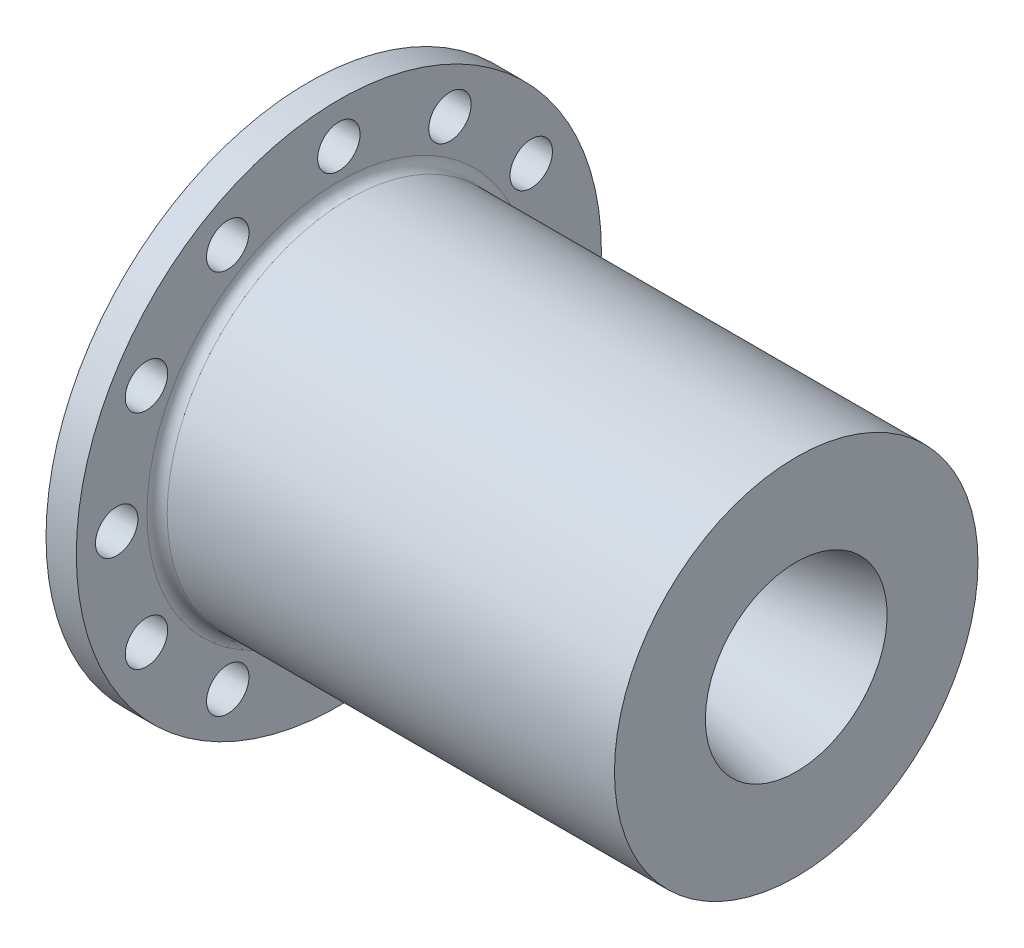
from build123d import *

# Parameters (mm, degrees)
FILLET1_R          = 1.27
SKETCH2_R          = 2.667
CUT_EXTRUDE1_DEPTH = 3.81
CIRPATTERN1_COUNT  = 12
FILLET2_R          = 0.254


with BuildPart() as part:
    # Chamber Revolve → Revolve1 (revolve)
    with BuildSketch(Plane.XY):
        Polygon((3.81, 22.86), (61.331753256, 22.86), (61.331753256, 11.43), (43.197991731, 7.57555), (41.673991731, 7.57555), (38.1, 15.24), (0, 15.24), (0, 19.304), (1.016, 19.304), (1.016, 21.844), (0, 21.844), (0, 33.02), (3.81, 33.02), align=None)
    revolve(axis=Axis((0, 0, 0), (1, 0, 0)))

    # Fillet1
    fillet1_edges = [part.edges().sort_by_distance(p)[0] for p in [
        (3.81, -22.86, 0),
    ]]
    fillet(fillet1_edges, radius=FILLET1_R)

    # Sketch2 → Cut-Extrude1 (cut)
    with BuildSketch(Plane.ZY):
        with Locations((0, 27.94)):
            Circle(SKETCH2_R)
    cut_extrude1 = extrude(amount=-CUT_EXTRUDE1_DEPTH, mode=Mode.SUBTRACT)

    # CirPattern1: Cut-Extrude1 ×12 about axis
    cirpattern1_axis = Axis((0, 0, 0), (1, 0, 0))
    for i in range(1, CIRPATTERN1_COUNT):
        add(cut_extrude1.rotate(cirpattern1_axis, i * 360 / CIRPATTERN1_COUNT), mode=Mode.SUBTRACT)

    # Fillet2
    fillet2_edges = [part.edges().sort_by_distance(p)[0] for p in [
        (1.016, -19.304, 0),
        (1.016, -21.844, 0),
    ]]
    fillet(fillet2_edges, radius=FILLET2_R)


solid = part.part
